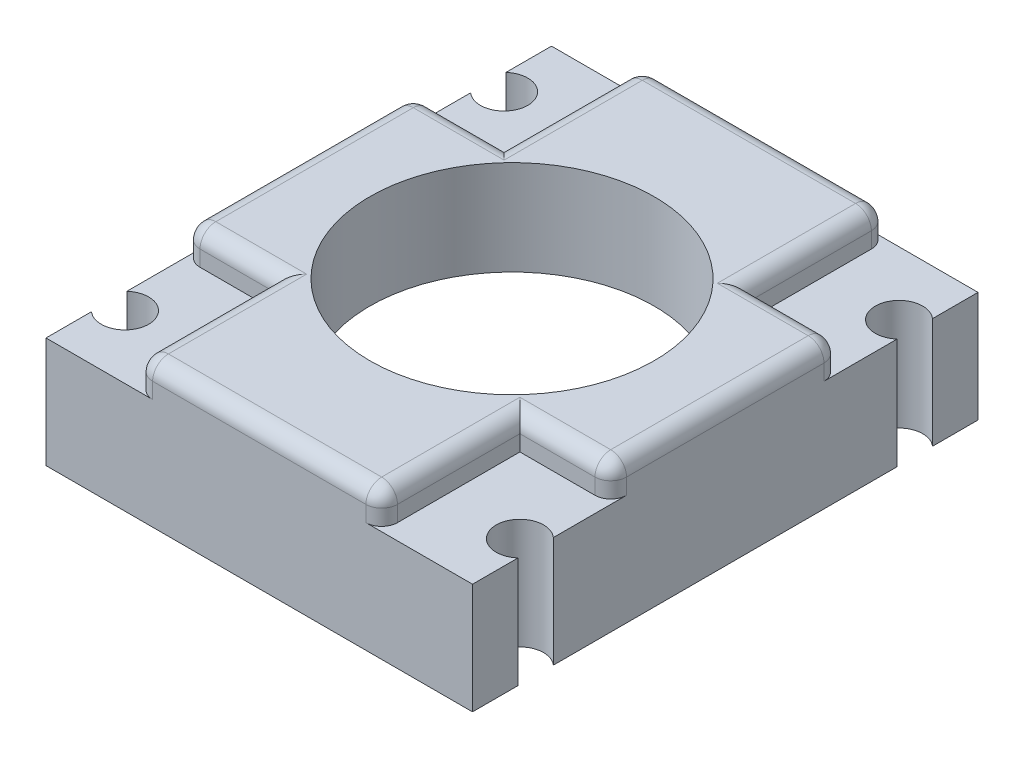
from build123d import *

# Parameters (mm, degrees)
SKETCH2_W               = 27
SKETCH2_H               = 32
SKETCH2_R               = 9
BOSS_EXTRUDE1_DEPTH     = 6
SKETCH3_W               = 27
SKETCH3_H               = 32
SKETCH3_W_2             = 25
SKETCH3_H_2             = 30
BOSS_EXTRUDE2_DEPTH     = 3
SKETCH1_R               = 1.5
CUT_EXTRUDE1_DEPTH      = 7
CUT_EXTRUDE1_DEPTH_BACK = 4
BOSS_EXTRUDE4_DEPTH     = 9
MIRROR2_COPY_1_DEPTH    = 9
SKETCH6_R               = 2.8
CUT_EXTRUDE2_DEPTH      = 2
MIRROR4_COPY_1_SKETCH_R = 2.8
MIRROR4_COPY_1_DEPTH    = 2
FILLET1_R               = 1
SKETCH11_W              = 9.5
SKETCH11_H              = 9.5
CUT_EXTRUDE3_DEPTH      = 2
MIRROR6_COPY_1_SKETCH_W = 9.5
MIRROR6_COPY_1_SKETCH_H = 9.5
MIRROR6_COPY_1_DEPTH    = 2
FILLET2_R               = 1


with BuildPart() as part:
    # Sketch2 → Boss-Extrude1 (new body)
    with BuildSketch(Plane(origin=(0, 0, 0), x_dir=(1, 0, 0), z_dir=(0, 1, 0))):
        Rectangle(SKETCH2_W, SKETCH2_H)
        Circle(SKETCH2_R, mode=Mode.SUBTRACT)
    extrude(amount=BOSS_EXTRUDE1_DEPTH)

    # Sketch3 → Boss-Extrude2 (add)
    with BuildSketch(Plane.XZ):
        Rectangle(SKETCH3_W, SKETCH3_H)
        Rectangle(SKETCH3_W_2, SKETCH3_H_2, mode=Mode.SUBTRACT)
    extrude(amount=BOSS_EXTRUDE2_DEPTH)

    # Sketch1 → Cut-Extrude1 (cut, two sides)
    with BuildSketch(Plane(origin=(0, 0, 0), x_dir=(1, 0, 0), z_dir=(0, 1, 0))) as cut_extrude1_sk:
        with Locations((-12.5, 12)):
            Circle(SKETCH1_R)
        with Locations((12.5, 12)):
            Circle(SKETCH1_R)
        with Locations((-12.5, -12)):
            Circle(SKETCH1_R)
        with Locations((12.5, -12)):
            Circle(SKETCH1_R)
    extrude(amount=CUT_EXTRUDE1_DEPTH, mode=Mode.SUBTRACT)
    extrude(cut_extrude1_sk.sketch, amount=-CUT_EXTRUDE1_DEPTH_BACK, mode=Mode.SUBTRACT)

    # Sketch5 → Boss-Extrude4 (add)
    with BuildSketch(Plane.XZ.offset(3)):
        with BuildLine():
            Line((13.5, -10.881966011), (13.5, -9.708712153))
            ThreePointArc((13.5, -9.708712153), (10, -12), (13.5, -14.291287847))
            Line((13.5, -14.291287847), (13.5, -13.118033989))
            ThreePointArc((13.5, -13.118033989), (11, -12), (13.5, -10.881966011))
        make_face()
    boss_extrude4 = extrude(amount=-BOSS_EXTRUDE4_DEPTH)

    # Mirror1: Boss-Extrude4 across plane
    add(boss_extrude4.mirror(Plane(origin=(0, 0, 0), x_dir=(0, 0, 1), z_dir=(1, 0, 0))))

    # Mirror2: Boss-Extrude4 across plane
    add(boss_extrude4.mirror(Plane.XY))

    # Mirror2 copy 1 sketch → Mirror2 copy 1 (add)
    with BuildSketch(Plane(origin=(0, -3, 0), x_dir=(-1, 0, 0), z_dir=(0, -1, 0))):
        with BuildLine():
            Line((13.5, -10.881966011), (13.5, -9.708712153))
            ThreePointArc((13.5, -9.708712153), (10, -12), (13.5, -14.291287847))
            Line((13.5, -14.291287847), (13.5, -13.118033989))
            ThreePointArc((13.5, -13.118033989), (11, -12), (13.5, -10.881966011))
        make_face()
    extrude(amount=-MIRROR2_COPY_1_DEPTH)

    # Sketch6 → Cut-Extrude2 (cut)
    with BuildSketch(Plane(origin=(0, 6, 0), x_dir=(1, 0, 0), z_dir=(0, 1, 0))):
        with Locations((12.5, 12)):
            Circle(SKETCH6_R)
    cut_extrude2 = extrude(amount=-CUT_EXTRUDE2_DEPTH, mode=Mode.SUBTRACT)

    # Mirror3: Cut-Extrude2 across plane
    add(cut_extrude2.mirror(Plane(origin=(0, 0, 0), x_dir=(0, 0, 1), z_dir=(1, 0, 0))), mode=Mode.SUBTRACT)

    # Mirror4: Cut-Extrude2 across plane
    add(cut_extrude2.mirror(Plane.XY), mode=Mode.SUBTRACT)

    # Mirror4 copy 1 sketch → Mirror4 copy 1 (cut)
    with BuildSketch(Plane(origin=(0, 6, 0), x_dir=(-1, 0, 0), z_dir=(0, 1, 0))):
        with Locations((12.5, 12)):
            Circle(MIRROR4_COPY_1_SKETCH_R)
    extrude(amount=-MIRROR4_COPY_1_DEPTH, mode=Mode.SUBTRACT)

    # Fillet1
    fillet1_edges = [part.edges().sort_by_distance(p)[0] for p in [
        (-13.5, 6, -15.307669683),
        (13.5, 6, -15.307669683),
        (0, 6, 16),
        (-13.5, 6, 0),
        (13.5, 6, 0),
        (-13.5, 6, 15.307669683),
        (13.5, 6, 15.307669683),
        (0, 6, -16),
    ]]
    fillet(fillet1_edges, radius=FILLET1_R)

    # Sketch11 → Cut-Extrude3 (cut)
    with BuildSketch(Plane(origin=(0, 6, 0), x_dir=(1, 0, 0), z_dir=(0, 1, 0))):
        with Locations((-12.5, -12)):
            Rectangle(SKETCH11_W, SKETCH11_H)
    cut_extrude3 = extrude(amount=-CUT_EXTRUDE3_DEPTH, mode=Mode.SUBTRACT)

    # Mirror5: Cut-Extrude3 across plane
    add(cut_extrude3.mirror(Plane(origin=(0, 0, 0), x_dir=(0, 0, 1), z_dir=(1, 0, 0))), mode=Mode.SUBTRACT)

    # Mirror6: Cut-Extrude3 across plane
    add(cut_extrude3.mirror(Plane.XY), mode=Mode.SUBTRACT)

    # Mirror6 copy 1 sketch → Mirror6 copy 1 (cut)
    with BuildSketch(Plane(origin=(0, 6, 0), x_dir=(-1, 0, 0), z_dir=(0, 1, 0))):
        with Locations((-12.5, -12)):
            Rectangle(MIRROR6_COPY_1_SKETCH_W, MIRROR6_COPY_1_SKETCH_H)
    extrude(amount=-MIRROR6_COPY_1_DEPTH, mode=Mode.SUBTRACT)

    # Fillet2
    fillet2_edges = [part.edges().sort_by_distance(p)[0] for p in [
        (-7.75, 4.5, 16),
        (-13.5, 4.5, 7.25),
        (-7.75, 6, 11.125),
        (-10.125, 6, 7.25),
        (7.75, 6, 11.125),
        (10.125, 6, 7.25),
        (7.75, 4.5, 16),
        (13.5, 4.5, 7.25),
        (13.5, 4.5, -7.25),
        (7.75, 4.5, -16),
        (7.75, 6, -11.125),
        (10.125, 6, -7.25),
        (-7.75, 6, -11.125),
        (-10.125, 6, -7.25),
        (-7.75, 4.5, -16),
        (-13.5, 4.5, -7.25),
    ]]
    fillet(fillet2_edges, radius=FILLET2_R)


solid = part.part
